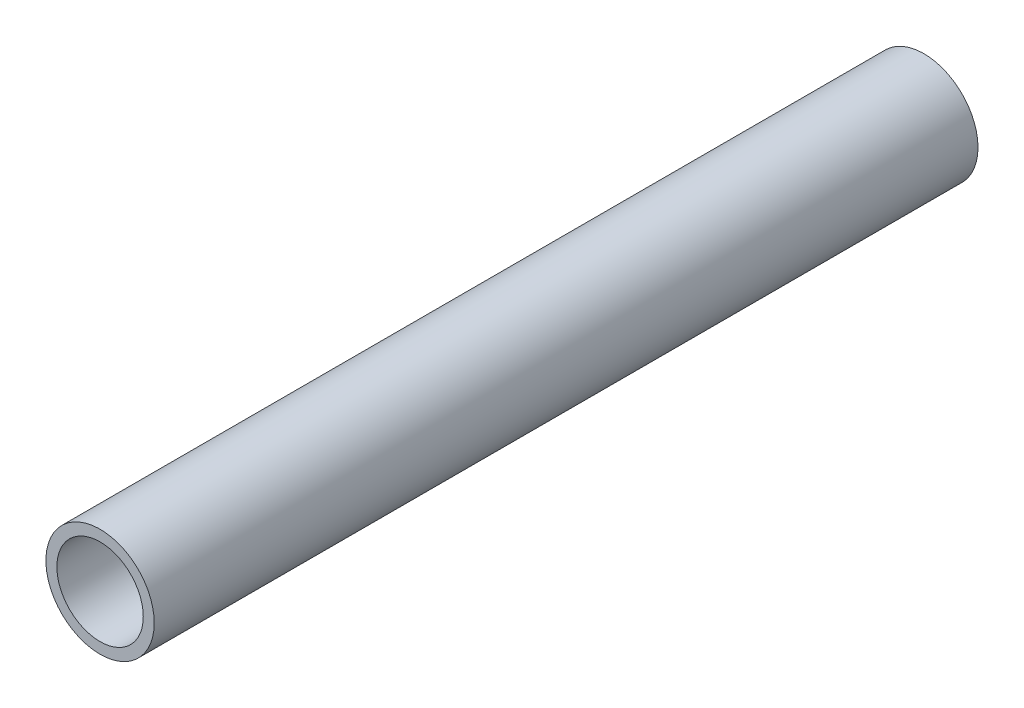
from build123d import *

# Parameters (mm, degrees)
SKETCH1_R           = 16.7005
SKETCH1_R_2         = 13.3223
EXTRUDE_THIN1_DEPTH = 127


with BuildPart() as part:
    # Sketch1 → Extrude-Thin1 (new body, symmetric)
    with BuildSketch(Plane.XY):
        Circle(SKETCH1_R)
        Circle(SKETCH1_R_2, mode=Mode.SUBTRACT)
    extrude(amount=EXTRUDE_THIN1_DEPTH, both=True)


solid = part.part
